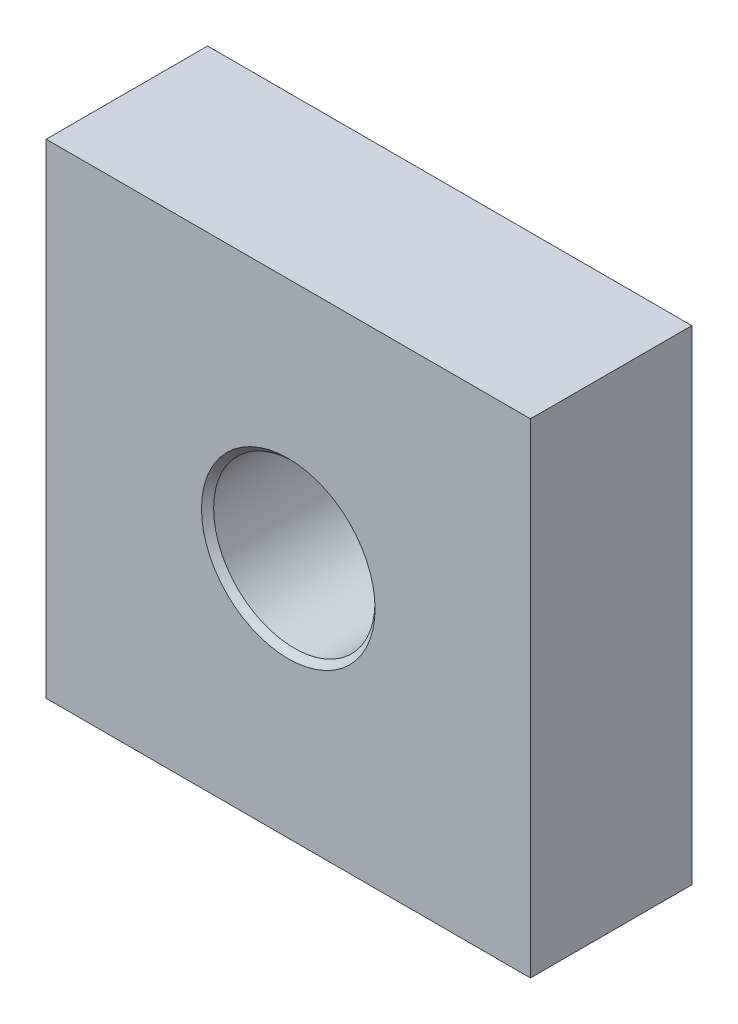
from build123d import *

# Parameters (mm, degrees)
SKETCH1_W          = 120
SKETCH1_H          = 120
SKETCH1_R          = 20
EXTRUDE1_DEPTH     = 20
FRAME_CHAMFER_SIZE = 1.5


with BuildPart() as part:
    # Sketch1 → Extrude1 (new body, symmetric)
    with BuildSketch(Plane.XY):
        Rectangle(SKETCH1_W, SKETCH1_H)
        Circle(SKETCH1_R, mode=Mode.SUBTRACT)
    extrude(amount=EXTRUDE1_DEPTH, both=True)

    # Frame Chamfer
    frame_chamfer_edges = [part.edges().sort_by_distance(p)[0] for p in [
        (-20, 0, -20),
        (-20, 0, 20),
    ]]
    chamfer(frame_chamfer_edges, length=FRAME_CHAMFER_SIZE)


solid = part.part
